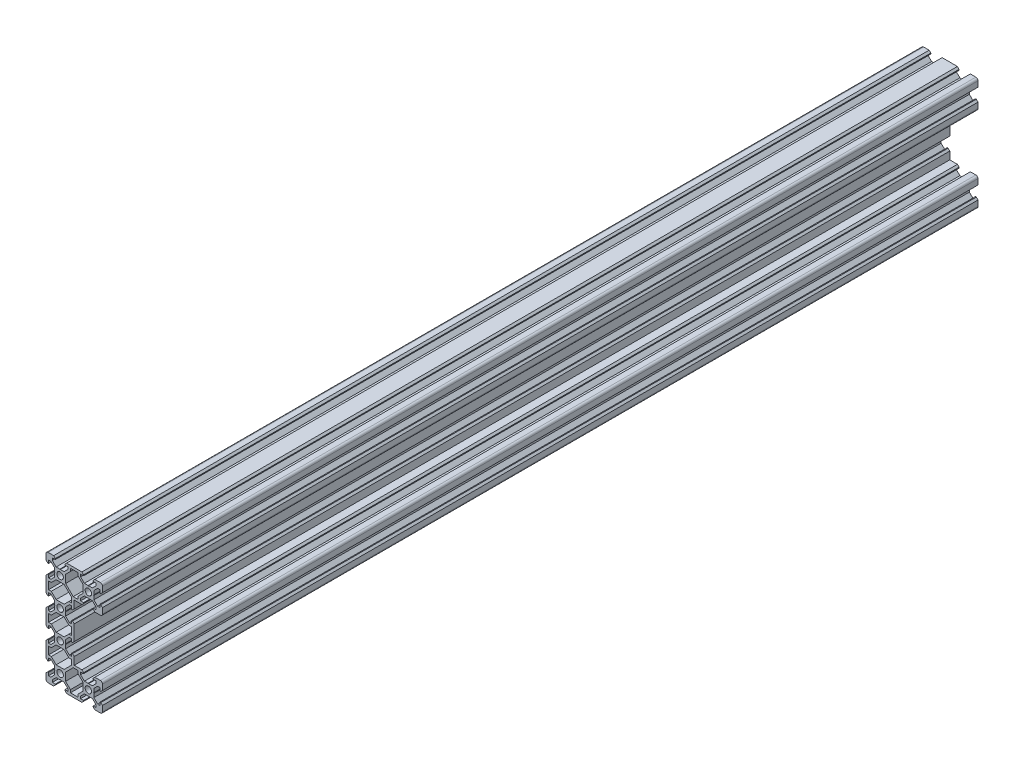
from build123d import *

# Parameters (mm, degrees)
SKETCH1_R           = 2.3
BOSS_EXTRUDE1_DEPTH = 620


with BuildPart() as part:
    # Sketch1 → Boss-Extrude1 (new body)
    with BuildSketch(Plane.XY):
        with BuildLine():
            Line((-20, -34.58), (-20, -38.5))
            ThreePointArc((-20, -38.5), (-19.560660172, -39.560660172), (-18.5, -40))
            Line((-18.5, -40), (-14.58, -40))
            Line((-14.58, -40), (-13.395, -38.815))
            Line((-13.395, -38.815), (-13.395, -38.2))
            Line((-13.395, -38.2), (-15.5, -38.2))
            Line((-15.5, -38.2), (-15.5, -36.560660172))
            Line((-15.5, -36.560660172), (-12.839339828, -33.9))
            Line((-12.839339828, -33.9), (-10.21, -33.9))
            Line((-10.21, -33.9), (-10, -33.69))
            Line((-10, -33.69), (-9.79, -33.9))
            Line((-9.79, -33.9), (-7.160660172, -33.9))
            Line((-7.160660172, -33.9), (-4.5, -36.560660172))
            Line((-4.5, -36.560660172), (-4.5, -38.2))
            Line((-4.5, -38.2), (-6.605, -38.2))
            Line((-6.605, -38.2), (-6.605, -38.815))
            Line((-6.605, -38.815), (-5.42, -40))
            Line((-5.42, -40), (5.42, -40))
            Line((5.42, -40), (6.605, -38.815))
            Line((6.605, -38.815), (6.605, -38.2))
            Line((6.605, -38.2), (4.5, -38.2))
            Line((4.5, -38.2), (4.5, -36.560660172))
            Line((4.5, -36.560660172), (7.160660172, -33.9))
            Line((7.160660172, -33.9), (9.79, -33.9))
            Line((9.79, -33.9), (10, -33.69))
            Line((10, -33.69), (10.21, -33.9))
            Line((10.21, -33.9), (12.839339828, -33.9))
            Line((12.839339828, -33.9), (15.5, -36.560660172))
            Line((15.5, -36.560660172), (15.5, -38.2))
            Line((15.5, -38.2), (13.395, -38.2))
            Line((13.395, -38.2), (13.395, -38.815))
            Line((13.395, -38.815), (14.58, -40))
            Line((14.58, -40), (18.5, -40))
            ThreePointArc((18.5, -40), (19.560660172, -39.560660172), (20, -38.5))
            Line((20, -38.5), (20, -34.58))
            Line((20, -34.58), (18.815, -33.395))
            Line((18.815, -33.395), (18.2, -33.395))
            Line((18.2, -33.395), (18.2, -35.5))
            Line((18.2, -35.5), (16.560660172, -35.5))
            Line((16.560660172, -35.5), (13.9, -32.839339828))
            Line((13.9, -32.839339828), (13.9, -30.21))
            Line((13.9, -30.21), (13.69, -30))
            Line((13.69, -30), (13.9, -29.79))
            Line((13.9, -29.79), (13.9, -27.160660172))
            Line((13.9, -27.160660172), (16.560660172, -24.5))
            Line((16.560660172, -24.5), (18.2, -24.5))
            Line((18.2, -24.5), (18.2, -26.605))
            Line((18.2, -26.605), (18.815, -26.605))
            Line((18.815, -26.605), (20, -25.42))
            Line((20, -25.42), (20, -21.5))
            ThreePointArc((20, -21.5), (19.560660172, -20.439339828), (18.5, -20))
            Line((18.5, -20), (14.58, -20))
            Line((14.58, -20), (13.395, -21.185))
            Line((13.395, -21.185), (13.395, -21.8))
            Line((13.395, -21.8), (15.5, -21.8))
            Line((15.5, -21.8), (15.5, -23.439339828))
            Line((15.5, -23.439339828), (12.839339828, -26.1))
            Line((12.839339828, -26.1), (10.21, -26.1))
            Line((10.21, -26.1), (10, -26.31))
            Line((10, -26.31), (9.79, -26.1))
            Line((9.79, -26.1), (7.160660172, -26.1))
            Line((7.160660172, -26.1), (4.5, -23.439339828))
            Line((4.5, -23.439339828), (4.5, -21.8))
            Line((4.5, -21.8), (6.605, -21.8))
            Line((6.605, -21.8), (6.605, -21.185))
            Line((6.605, -21.185), (5.42, -20))
            Line((5.42, -20), (0, -20))
            Line((0, -20), (0, -14.58))
            Line((0, -14.58), (-1.185, -13.395))
            Line((-1.185, -13.395), (-1.8, -13.395))
            Line((-1.8, -13.395), (-1.8, -15.5))
            Line((-1.8, -15.5), (-3.439339828, -15.5))
            Line((-3.439339828, -15.5), (-6.1, -12.839339828))
            Line((-6.1, -12.839339828), (-6.1, -10.21))
            Line((-6.1, -10.21), (-6.31, -10))
            Line((-6.31, -10), (-6.1, -9.79))
            Line((-6.1, -9.79), (-6.1, -7.160660172))
            Line((-6.1, -7.160660172), (-3.439339828, -4.5))
            Line((-3.439339828, -4.5), (-1.8, -4.5))
            Line((-1.8, -4.5), (-1.8, -6.605))
            Line((-1.8, -6.605), (-1.185, -6.605))
            Line((-1.185, -6.605), (0, -5.42))
            Line((0, -5.42), (0, 5.42))
            Line((0, 5.42), (-1.185, 6.605))
            Line((-1.185, 6.605), (-1.8, 6.605))
            Line((-1.8, 6.605), (-1.8, 4.5))
            Line((-1.8, 4.5), (-3.439339828, 4.5))
            Line((-3.439339828, 4.5), (-6.1, 7.160660172))
            Line((-6.1, 7.160660172), (-6.1, 9.79))
            Line((-6.1, 9.79), (-6.31, 10))
            Line((-6.31, 10), (-6.1, 10.21))
            Line((-6.1, 10.21), (-6.1, 12.839339828))
            Line((-6.1, 12.839339828), (-3.439339828, 15.5))
            Line((-3.439339828, 15.5), (-1.8, 15.5))
            Line((-1.8, 15.5), (-1.8, 13.395))
            Line((-1.8, 13.395), (-1.185, 13.395))
            Line((-1.185, 13.395), (0, 14.58))
            Line((0, 14.58), (0, 20))
            Line((0, 20), (5.42, 20))
            Line((5.42, 20), (6.605, 21.185))
            Line((6.605, 21.185), (6.605, 21.8))
            Line((6.605, 21.8), (4.5, 21.8))
            Line((4.5, 21.8), (4.5, 23.439339828))
            Line((4.5, 23.439339828), (7.160660172, 26.1))
            Line((7.160660172, 26.1), (9.79, 26.1))
            Line((9.79, 26.1), (10, 26.31))
            Line((10, 26.31), (10.21, 26.1))
            Line((10.21, 26.1), (12.839339828, 26.1))
            Line((12.839339828, 26.1), (15.5, 23.439339828))
            Line((15.5, 23.439339828), (15.5, 21.8))
            Line((15.5, 21.8), (13.395, 21.8))
            Line((13.395, 21.8), (13.395, 21.185))
            Line((13.395, 21.185), (14.58, 20))
            Line((14.58, 20), (18.5, 20))
            ThreePointArc((18.5, 20), (19.560660172, 20.439339828), (20, 21.5))
            Line((20, 21.5), (20, 25.42))
            Line((20, 25.42), (18.815, 26.605))
            Line((18.815, 26.605), (18.2, 26.605))
            Line((18.2, 26.605), (18.2, 24.5))
            Line((18.2, 24.5), (16.560660172, 24.5))
            Line((16.560660172, 24.5), (13.9, 27.160660172))
            Line((13.9, 27.160660172), (13.9, 29.79))
            Line((13.9, 29.79), (13.69, 30))
            Line((13.69, 30), (13.9, 30.21))
            Line((13.9, 30.21), (13.9, 32.839339828))
            Line((13.9, 32.839339828), (16.560660172, 35.5))
            Line((16.560660172, 35.5), (18.2, 35.5))
            Line((18.2, 35.5), (18.2, 33.395))
            Line((18.2, 33.395), (18.815, 33.395))
            Line((18.815, 33.395), (20, 34.58))
            Line((20, 34.58), (20, 38.5))
            ThreePointArc((20, 38.5), (19.560660172, 39.560660172), (18.5, 40))
            Line((18.5, 40), (14.58, 40))
            Line((14.58, 40), (13.395, 38.815))
            Line((13.395, 38.815), (13.395, 38.2))
            Line((13.395, 38.2), (15.5, 38.2))
            Line((15.5, 38.2), (15.5, 36.560660172))
            Line((15.5, 36.560660172), (12.839339828, 33.9))
            Line((12.839339828, 33.9), (10.21, 33.9))
            Line((10.21, 33.9), (10, 33.69))
            Line((10, 33.69), (9.79, 33.9))
            Line((9.79, 33.9), (7.160660172, 33.9))
            Line((7.160660172, 33.9), (4.5, 36.560660172))
            Line((4.5, 36.560660172), (4.5, 38.2))
            Line((4.5, 38.2), (6.605, 38.2))
            Line((6.605, 38.2), (6.605, 38.815))
            Line((6.605, 38.815), (5.42, 40))
            Line((5.42, 40), (-5.42, 40))
            Line((-5.42, 40), (-6.605, 38.815))
            Line((-6.605, 38.815), (-6.605, 38.2))
            Line((-6.605, 38.2), (-4.5, 38.2))
            Line((-4.5, 38.2), (-4.5, 36.560660172))
            Line((-4.5, 36.560660172), (-7.160660172, 33.9))
            Line((-7.160660172, 33.9), (-9.79, 33.9))
            Line((-9.79, 33.9), (-10, 33.69))
            Line((-10, 33.69), (-10.21, 33.9))
            Line((-10.21, 33.9), (-12.839339828, 33.9))
            Line((-12.839339828, 33.9), (-15.5, 36.560660172))
            Line((-15.5, 36.560660172), (-15.5, 38.2))
            Line((-15.5, 38.2), (-13.395, 38.2))
            Line((-13.395, 38.2), (-13.395, 38.815))
            Line((-13.395, 38.815), (-14.58, 40))
            Line((-14.58, 40), (-18.5, 40))
            ThreePointArc((-18.5, 40), (-19.560660172, 39.560660172), (-20, 38.5))
            Line((-20, 38.5), (-20, 34.58))
            Line((-20, 34.58), (-18.815, 33.395))
            Line((-18.815, 33.395), (-18.2, 33.395))
            Line((-18.2, 33.395), (-18.2, 35.5))
            Line((-18.2, 35.5), (-16.560660172, 35.5))
            Line((-16.560660172, 35.5), (-13.9, 32.839339828))
            Line((-13.9, 32.839339828), (-13.9, 30.21))
            Line((-13.9, 30.21), (-13.69, 30))
            Line((-13.69, 30), (-13.9, 29.79))
            Line((-13.9, 29.79), (-13.9, 27.160660172))
            Line((-13.9, 27.160660172), (-16.560660172, 24.5))
            Line((-16.560660172, 24.5), (-18.2, 24.5))
            Line((-18.2, 24.5), (-18.2, 26.605))
            Line((-18.2, 26.605), (-18.815, 26.605))
            Line((-18.815, 26.605), (-20, 25.42))
            Line((-20, 25.42), (-20, 14.58))
            Line((-20, 14.58), (-18.815, 13.395))
            Line((-18.815, 13.395), (-18.2, 13.395))
            Line((-18.2, 13.395), (-18.2, 15.5))
            Line((-18.2, 15.5), (-16.560660172, 15.5))
            Line((-16.560660172, 15.5), (-13.9, 12.839339828))
            Line((-13.9, 12.839339828), (-13.9, 10.21))
            Line((-13.9, 10.21), (-13.69, 10))
            Line((-13.69, 10), (-13.9, 9.79))
            Line((-13.9, 9.79), (-13.9, 7.160660172))
            Line((-13.9, 7.160660172), (-16.560660172, 4.5))
            Line((-16.560660172, 4.5), (-18.2, 4.5))
            Line((-18.2, 4.5), (-18.2, 6.605))
            Line((-18.2, 6.605), (-18.815, 6.605))
            Line((-18.815, 6.605), (-20, 5.42))
            Line((-20, 5.42), (-20, -5.42))
            Line((-20, -5.42), (-18.815, -6.605))
            Line((-18.815, -6.605), (-18.2, -6.605))
            Line((-18.2, -6.605), (-18.2, -4.5))
            Line((-18.2, -4.5), (-16.560660172, -4.5))
            Line((-16.560660172, -4.5), (-13.9, -7.160660172))
            Line((-13.9, -7.160660172), (-13.9, -9.79))
            Line((-13.9, -9.79), (-13.69, -10))
            Line((-13.69, -10), (-13.9, -10.21))
            Line((-13.9, -10.21), (-13.9, -12.839339828))
            Line((-13.9, -12.839339828), (-16.560660172, -15.5))
            Line((-16.560660172, -15.5), (-18.2, -15.5))
            Line((-18.2, -15.5), (-18.2, -13.395))
            Line((-18.2, -13.395), (-18.815, -13.395))
            Line((-18.815, -13.395), (-20, -14.58))
            Line((-20, -14.58), (-20, -25.42))
            Line((-20, -25.42), (-18.815, -26.605))
            Line((-18.815, -26.605), (-18.2, -26.605))
            Line((-18.2, -26.605), (-18.2, -24.5))
            Line((-18.2, -24.5), (-16.560660172, -24.5))
            Line((-16.560660172, -24.5), (-13.9, -27.160660172))
            Line((-13.9, -27.160660172), (-13.9, -29.79))
            Line((-13.9, -29.79), (-13.69, -30))
            Line((-13.69, -30), (-13.9, -30.21))
            Line((-13.9, -30.21), (-13.9, -32.839339828))
            Line((-13.9, -32.839339828), (-16.560660172, -35.5))
            Line((-16.560660172, -35.5), (-18.2, -35.5))
            Line((-18.2, -35.5), (-18.2, -33.395))
            Line((-18.2, -33.395), (-18.815, -33.395))
            Line((-18.815, -33.395), (-20, -34.58))
        make_face()
        with Locations((-10, -30)):
            Circle(SKETCH1_R, mode=Mode.SUBTRACT)
        Polygon((-16.239339828, -22.7), (-18.2, -22.7), (-18.2, -17.3), (-16.239339828, -17.3), (-12.839339828, -13.9), (-7.160660172, -13.9), (-3.760660172, -17.3), (-1.8, -17.3), (-1.8, -20.739339828), (-7.160660172, -26.1), (-12.839339828, -26.1), align=None, mode=Mode.SUBTRACT)
        with Locations((-10, -10)):
            Circle(SKETCH1_R, mode=Mode.SUBTRACT)
        Polygon((2.7, -36.239339828), (2.7, -38.2), (-2.7, -38.2), (-2.7, -36.239339828), (-6.1, -32.839339828), (-6.1, -27.160660172), (-0.739339828, -21.8), (2.7, -21.8), (2.7, -23.760660172), (6.1, -27.160660172), (6.1, -32.839339828), align=None, mode=Mode.SUBTRACT)
        with Locations((10, -30)):
            Circle(SKETCH1_R, mode=Mode.SUBTRACT)
        Polygon((-16.239339828, -2.7), (-18.2, -2.7), (-18.2, 2.7), (-16.239339828, 2.7), (-12.839339828, 6.1), (-7.160660172, 6.1), (-3.760660172, 2.7), (-1.8, 2.7), (-1.8, -2.7), (-3.760660172, -2.7), (-7.160660172, -6.1), (-12.839339828, -6.1), align=None, mode=Mode.SUBTRACT)
        with Locations((-10, 10)):
            Circle(SKETCH1_R, mode=Mode.SUBTRACT)
        Polygon((-16.239339828, 17.3), (-18.2, 17.3), (-18.2, 22.7), (-16.239339828, 22.7), (-12.839339828, 26.1), (-7.160660172, 26.1), (-1.8, 20.739339828), (-1.8, 17.3), (-3.760660172, 17.3), (-7.160660172, 13.9), (-12.839339828, 13.9), align=None, mode=Mode.SUBTRACT)
        with Locations((-10, 30)):
            Circle(SKETCH1_R, mode=Mode.SUBTRACT)
        Polygon((-2.7, 36.239339828), (-2.7, 38.2), (2.7, 38.2), (2.7, 36.239339828), (6.1, 32.839339828), (6.1, 27.160660172), (2.7, 23.760660172), (2.7, 21.8), (-0.739339828, 21.8), (-6.1, 27.160660172), (-6.1, 32.839339828), align=None, mode=Mode.SUBTRACT)
        with Locations((10, 30)):
            Circle(SKETCH1_R, mode=Mode.SUBTRACT)
    extrude(amount=BOSS_EXTRUDE1_DEPTH)


solid = part.part
